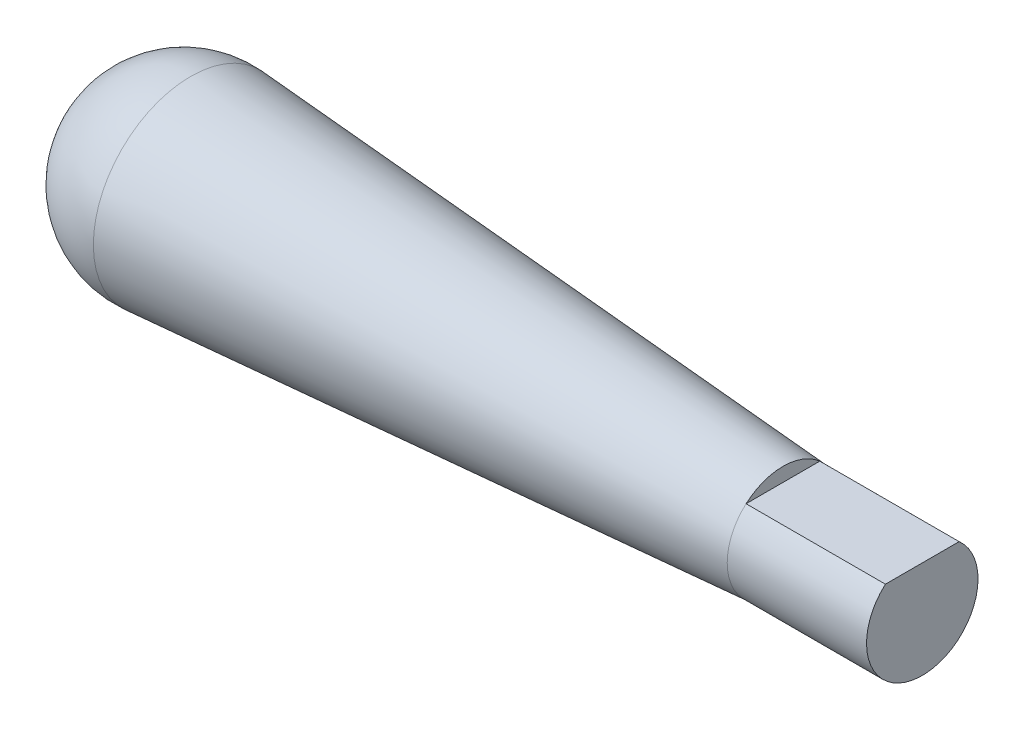
from build123d import *

# Parameters (mm, degrees)
IZIM3_W               = 17.291982939
IZIM3_H               = 2.660305068
KES_EKSTR_ZYON1_DEPTH = 10


with BuildPart() as part:
    # Çizim1 → Döndür1 (revolve)
    with BuildSketch(Plane.XY):
        with BuildLine():
            Line((0, 0), (60, 0))
            Line((60, 0), (60, 4))
            Line((60, 4), (50, 4))
            Line((50, 4), (7.4899692, 6.982831101))
            ThreePointArc((7.4899692, 6.982831101), (2.226625114, 5.120048066), (0, 0))
        make_face()
    revolve(axis=Axis((0, 0, 0), (1, 0, 0)))

    # Çizim3 → Kes-Ekstrüzyon1 (cut)
    with BuildSketch(Plane(origin=(60, 0, 0), x_dir=(0, 0, -1), z_dir=(1, 0, 0))):
        with Locations((0.048193933, 4.330152534)):
            Rectangle(IZIM3_W, IZIM3_H)
    extrude(amount=-KES_EKSTR_ZYON1_DEPTH, mode=Mode.SUBTRACT)


solid = part.part
